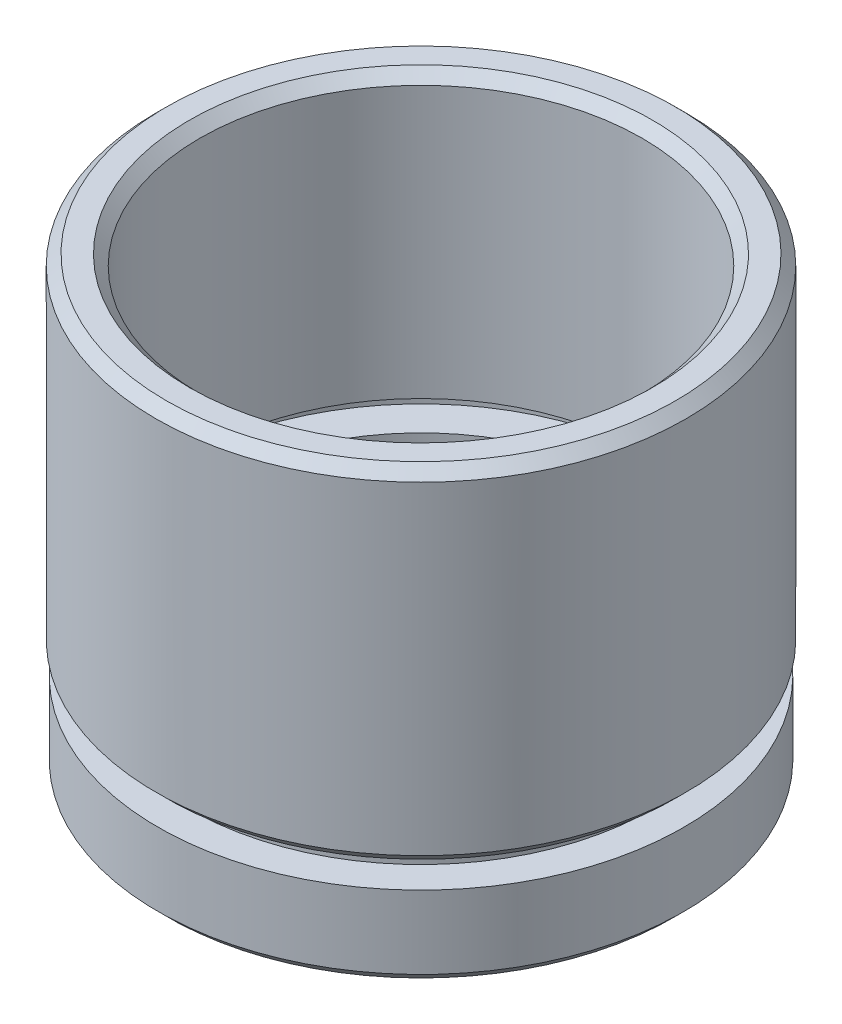
from build123d import *

# Parameters (mm, degrees)
CHAMFER_1_SIZE = 0.5


with BuildPart() as part:
    # 草图1 → 旋转1 (revolve)
    with BuildSketch(Plane.XY, mode=Mode.PRIVATE) as revolve_1_sk:
        Polygon((9.25, 0), (12.6, 0), (12.6, 4), (11.1, 4), (11.1, 5), (12.7, 5), (12.7, 21.5), (10.6, 21.5), (10.6, 8), (11.7, 8), (11.7, 7), (10, 7), (10, 2), (9.25, 2), align=None)
    revolve(revolve_1_sk.sketch.rotate(Axis((0, 0, 0), (0, 1, 0)), 90), axis=Axis((0, 0, 0), (0, 1, 0)))  # turned: the seam where the file's is

    # 倒角1
    chamfer_1_edges = [part.edges().sort_by_distance(p)[0] for p in [
        (0, 21.5, 10.6),
        (0, 21.5, 12.7),
        (0, 5, 12.7),
        (0, 0, 12.6),
    ]]
    chamfer(chamfer_1_edges, length=CHAMFER_1_SIZE)


solid = part.part
